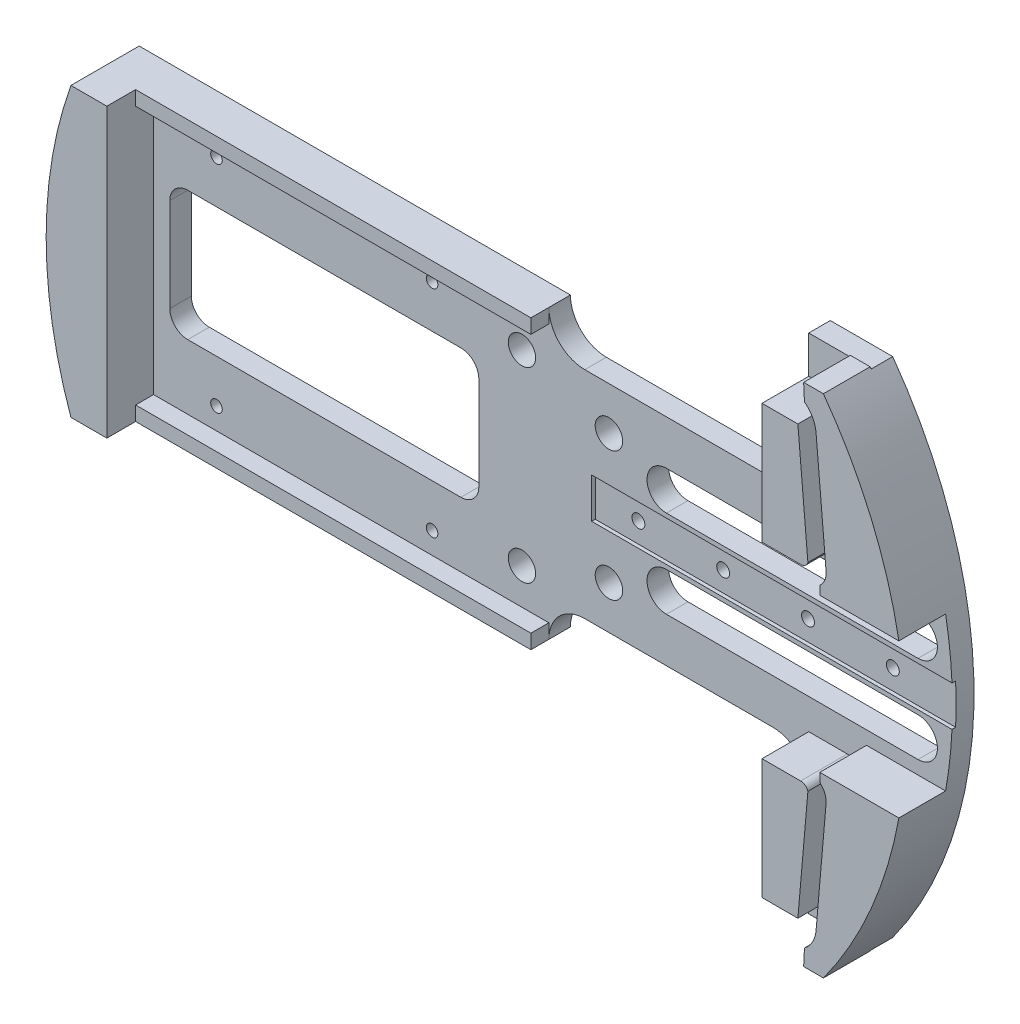
from build123d import *

# Parameters (mm, degrees)
BOSS_EXTRUDE1_DEPTH = 3.81
BOSS_EXTRUDE2_DEPTH = 8.255
SKETCH3_W           = 64.77
SKETCH3_H           = 7.1
CUT_EXTRUDE1_DEPTH  = 0.635
CUT_EXTRUDE4_DEPTH  = 4.81
CUT_EXTRUDE5_DEPTH  = 4.81
SKETCH12_R          = 2.4257
CUT_EXTRUDE6_DEPTH  = 4.81
SKETCH4_R           = 1.143
CUT_EXTRUDE2_DEPTH  = 11.43
SKETCH17_R          = 2.413
CUT_EXTRUDE9_DEPTH  = 4.81
BOSS_EXTRUDE5_DEPTH = 8.255
SKETCH20_W          = 69.85
SKETCH20_H          = 3.175
BOSS_EXTRUDE6_DEPTH = 2.54
SKETCH21_R          = 1.02235
CUT_EXTRUDE10_DEPTH = 13.065


with BuildPart() as part:
    # Sketch1 → Boss-Extrude1 (new body)
    with BuildSketch(Plane.XY):
        with BuildLine():
            Line((10.977415053, 19.05), (44.196, 19.05))
            ThreePointArc((44.196, 19.05), (48.686128061, 20.909871939), (50.546, 25.4))
            Line((50.546, 25.4), (50.546, 44.45))
            Line((50.546, 44.45), (61.579155694, 44.45))
            ThreePointArc((61.579155694, 44.45), (75.946, 0), (61.579155694, -44.45))
            Line((61.579155694, -44.45), (50.546, -44.45))
            Line((50.546, -44.45), (50.546, -25.4))
            ThreePointArc((50.546, -25.4), (48.686128061, -20.909871939), (44.196, -19.05))
            Line((44.196, -19.05), (10.977415053, -19.05))
            ThreePointArc((10.977415053, -19.05), (6.487286992, -20.909871939), (4.627415053, -25.4))
            Line((4.627415053, -25.4), (-71.572584947, -25.4))
            ThreePointArc((-71.572584947, -25.4), (-75.946, 0), (-71.572584947, 25.4))
            Line((-71.572584947, 25.4), (4.627415053, 25.4))
            ThreePointArc((4.627415053, 25.4), (6.487286992, 20.909871939), (10.977415053, 19.05))
        make_face()
    extrude(amount=BOSS_EXTRUDE1_DEPTH)

    # Sketch2 → Boss-Extrude2 (add)
    with BuildSketch(Plane.XY.offset(3.81)):
        with BuildLine():
            Line((61.865268471, 17.78), (60.095110466, 38.1))
            ThreePointArc((60.095110466, 38.1), (59.464196764, 40.158289632), (58.047089349, 41.778911391))
            Line((58.047089349, 41.778911391), (57.900800643, 44.704))
            Line((57.900800643, 44.704), (61.395010384, 44.704))
            ThreePointArc((61.395010384, 44.704), (69.822038137, 29.877715884), (74.728381149, 13.544887112))
            Line((74.728381149, 13.544887112), (60.759450402, 13.544887112))
            Line((60.759450402, 13.544887112), (60.759450402, 15.094127876))
            ThreePointArc((60.759450402, 15.094127876), (61.639191639, 16.302501703), (61.865268471, 17.78))
        make_face()
        with BuildLine():
            Line((58.651639318, 17.500047669), (56.881481313, 37.820047669))
            Line((56.881481313, 37.820047669), (50.546, 37.820047669))
            Line((50.546, 37.820047669), (50.546, 16.566735288))
            Line((50.546, 16.566735288), (57.366094516, 16.566735288))
            ThreePointArc((57.366094516, 16.566735288), (58.160401987, 16.824667019), (58.651639318, 17.500047669))
        make_face()
        with BuildLine():
            Line((60.759450402, -13.544887112), (74.728381149, -13.544887112))
            ThreePointArc((74.728381149, -13.544887112), (69.822038137, -29.877715884), (61.395010384, -44.704))
            Line((61.395010384, -44.704), (57.900800643, -44.704))
            Line((57.900800643, -44.704), (58.047089349, -41.778911391))
            ThreePointArc((58.047089349, -41.778911391), (59.464196764, -40.158289632), (60.095110466, -38.1))
            Line((60.095110466, -38.1), (61.865268471, -17.78))
            ThreePointArc((61.865268471, -17.78), (61.639191639, -16.302501703), (60.759450402, -15.094127876))
            Line((60.759450402, -15.094127876), (60.759450402, -13.544887112))
        make_face()
        with BuildLine():
            Line((50.546, -16.566735288), (57.366094516, -16.566735288))
            ThreePointArc((57.366094516, -16.566735288), (58.160401987, -16.824667019), (58.651639318, -17.500047669))
            Line((58.651639318, -17.500047669), (56.881481313, -37.820047669))
            Line((56.881481313, -37.820047669), (50.546, -37.820047669))
            Line((50.546, -37.820047669), (50.546, -16.566735288))
        make_face()
    extrude(amount=BOSS_EXTRUDE2_DEPTH)

    # Sketch3 → Cut-Extrude1 (cut)
    with BuildSketch(Plane.XY.offset(3.81)):
        with Locations((44.577, 0)):
            Rectangle(SKETCH3_W, SKETCH3_H)
    extrude(amount=-CUT_EXTRUDE1_DEPTH, mode=Mode.SUBTRACT)

    # Sketch9 → Cut-Extrude4 (cut, through all)
    with BuildSketch(Plane.XY.offset(3.81)):
        with BuildLine():
            Line((69.85, 11.17), (25.4, 11.17))
            ThreePointArc((25.4, 11.17), (21.971, 7.741), (25.4, 4.312))
            Line((25.4, 4.312), (69.85, 4.312))
            ThreePointArc((69.85, 4.312), (73.279, 7.741), (69.85, 11.17))
        make_face()
        with BuildLine():
            Line((69.85, -4.312), (25.4, -4.312))
            ThreePointArc((25.4, -4.312), (21.971, -7.741), (25.4, -11.17))
            Line((25.4, -11.17), (69.85, -11.17))
            ThreePointArc((69.85, -11.17), (73.279, -7.741), (69.85, -4.312))
        make_face()
    extrude(amount=-CUT_EXTRUDE4_DEPTH, mode=Mode.SUBTRACT)

    # Sketch10 → Cut-Extrude5 (cut, through all)
    with BuildSketch(Plane.XY.offset(3.81)):
        with BuildLine():
            Line((-10.922, 11.43), (-59.182, 11.43))
            ThreePointArc((-59.182, 11.43), (-61.42706403, 10.50006403), (-62.357, 8.255))
            Line((-62.357, 8.255), (-62.357, -8.255))
            ThreePointArc((-62.357, -8.255), (-61.42706403, -10.50006403), (-59.182, -11.43))
            Line((-59.182, -11.43), (-10.922, -11.43))
            ThreePointArc((-10.922, -11.43), (-8.67693597, -10.50006403), (-7.747, -8.255))
            Line((-7.747, -8.255), (-7.747, 8.255))
            ThreePointArc((-7.747, 8.255), (-8.67693597, 10.50006403), (-10.922, 11.43))
        make_face()
    extrude(amount=-CUT_EXTRUDE5_DEPTH, mode=Mode.SUBTRACT)

    # Sketch12 → Cut-Extrude6 (cut, through all)
    with BuildSketch(Plane.XY.offset(3.81)):
        with Locations((15.24, 11.43)):
            Circle(SKETCH12_R)
        with Locations((15.24, -11.43)):
            Circle(SKETCH12_R)
    extrude(amount=-CUT_EXTRUDE6_DEPTH, mode=Mode.SUBTRACT)

    # Sketch4 → Cut-Extrude2 (cut)
    with BuildSketch(Plane.XY.offset(3.175)):
        with Locations((19.812, 0)):
            Circle(SKETCH4_R)
        with Locations((34.798, 0)):
            Circle(SKETCH4_R)
        with Locations((49.784, 0)):
            Circle(SKETCH4_R)
        with Locations((64.77, 0)):
            Circle(SKETCH4_R)
    extrude(amount=-CUT_EXTRUDE2_DEPTH, mode=Mode.SUBTRACT)

    # Sketch17 → Cut-Extrude9 (cut, through all)
    with BuildSketch(Plane.XY.offset(3.81)):
        with Locations((-0.127, 16.51)):
            Circle(SKETCH17_R)
        with Locations((-0.127, -16.51)):
            Circle(SKETCH17_R)
    extrude(amount=-CUT_EXTRUDE9_DEPTH, mode=Mode.SUBTRACT)

    # Sketch19 → Boss-Extrude5 (add)
    with BuildSketch(Plane.XY.offset(3.81)):
        with BuildLine():
            Line((-71.572584947, -25.4), (-65.222584947, -25.4))
            Line((-65.222584947, -25.4), (-65.222584947, 25.4))
            Line((-65.222584947, 25.4), (-71.572584947, 25.4))
            ThreePointArc((-71.572584947, 25.4), (-75.946, 0), (-71.572584947, -25.4))
        make_face()
    extrude(amount=BOSS_EXTRUDE5_DEPTH)

    # Sketch20 → Boss-Extrude6 (add)
    with BuildSketch(Plane.XZ.offset(25.4)):
        with Locations((-30.297584947, 5.3975)):
            Rectangle(SKETCH20_W, SKETCH20_H)
    boss_extrude6 = extrude(amount=-BOSS_EXTRUDE6_DEPTH)

    # Mirror1: Boss-Extrude6 across plane
    add(boss_extrude6.mirror(Plane.ZX))

    # Sketch21 → Cut-Extrude10 (cut, through all)
    with BuildSketch(Plane(origin=(0, 0, 0), x_dir=(-1, 0, 0), z_dir=(0, 0, -1))):
        with Locations((54.102, 19.05)):
            Circle(SKETCH21_R)
        with Locations((16.002, 19.05)):
            Circle(SKETCH21_R)
        with Locations((16.002, -19.05)):
            Circle(SKETCH21_R)
        with Locations((54.102, -19.05)):
            Circle(SKETCH21_R)
    extrude(amount=-CUT_EXTRUDE10_DEPTH, mode=Mode.SUBTRACT)


solid = part.part
